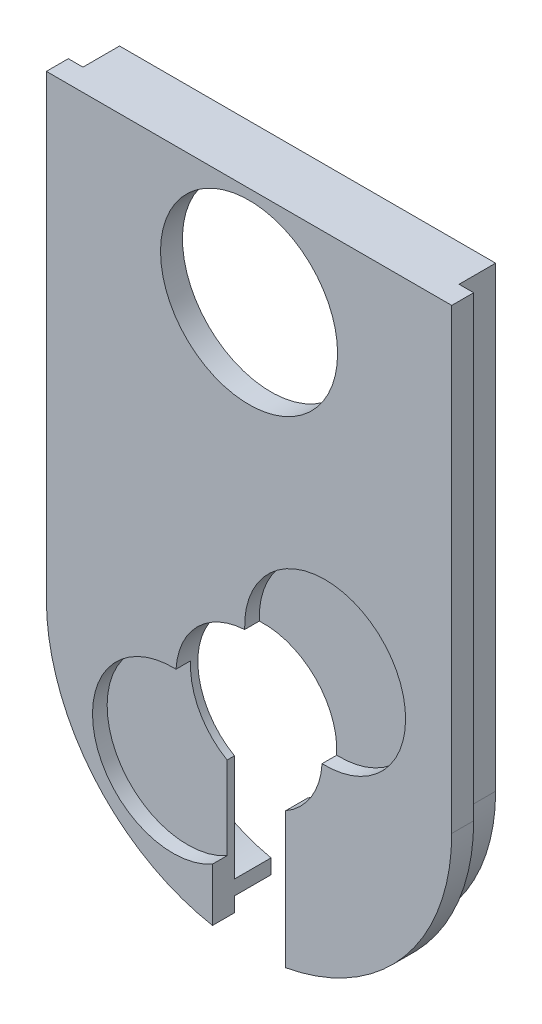
from build123d import *

# Parameters (mm, degrees)
SKETCH1_R           = 27.7
BOSS_EXTRUDE1_DEPTH = 3
SKETCH2_R           = 11
CUT_EXTRUDE1_DEPTH  = 2
SKETCH4_R           = 10
CUT_EXTRUDE2_DEPTH  = 3
SKETCH5_R           = 12.1
BOSS_EXTRUDE3_DEPTH = 3
SKETCH6_W           = 10
SKETCH6_H           = 27.7
CUT_EXTRUDE3_DEPTH  = 3
BOSS_EXTRUDE4_DEPTH = 5


with BuildPart() as part:
    # Sketch1 → Boss-Extrude1 (new body)
    with BuildSketch(Plane.XY):
        Circle(SKETCH1_R)
    extrude(amount=BOSS_EXTRUDE1_DEPTH)

    # Sketch2 → Cut-Extrude1 (cut)
    with BuildSketch(Plane.XY.offset(3)):
        with Locations((-10.394469683, -10.394469683)):
            Circle(SKETCH2_R)
        with Locations((10.394469683, 10.394469683)):
            Circle(SKETCH2_R)
    extrude(amount=-CUT_EXTRUDE1_DEPTH, mode=Mode.SUBTRACT)

    # Sketch4 → Cut-Extrude2 (cut)
    with BuildSketch(Plane.XY.offset(3)):
        Circle(SKETCH4_R)
    extrude(amount=-CUT_EXTRUDE2_DEPTH, mode=Mode.SUBTRACT)

    # Sketch6 → Cut-Extrude3 (cut)
    with BuildSketch(Plane.XY.offset(3)):
        with Locations((0, -13.85)):
            Rectangle(SKETCH6_W, SKETCH6_H)
    extrude(amount=-CUT_EXTRUDE3_DEPTH, mode=Mode.SUBTRACT)



with BuildPart() as body_2:
    # Sketch5 → Boss-Extrude3 (new body)
    with BuildSketch(Plane.XY.offset(3)):
        with BuildLine():
            Line((-27.7, 0), (-27.7, 62.5))
            Line((-27.7, 62.5), (27.7, 62.5))
            Line((27.7, 62.5), (27.7, 0))
            ThreePointArc((27.7, 0), (0, 27.7), (-27.7, 0))
        make_face()
        with Locations((0, 49)):
            Circle(SKETCH5_R, mode=Mode.SUBTRACT)
    extrude(amount=-BOSS_EXTRUDE3_DEPTH)


with BuildPart() as part_1:
    add(part.part)

    add(body_2.part)  # Boss-Extrude4 merges body 2
    # Sketch8 → Boss-Extrude4 (add)
    with BuildSketch(Plane(origin=(0, 0, 0), x_dir=(-1, 0, 0), z_dir=(0, 0, -1))):
        with BuildLine():
            Line((-23.7, 62.5), (23.7, 62.5))
            Line((23.7, 62.5), (25.7, 62.5))
            Line((25.7, 62.5), (25.7, 0))
            ThreePointArc((25.7, 0), (19.863362581, -16.32329625), (5, -25.244999541))
            Line((5, -25.244999541), (5, -23.244999541))
            ThreePointArc((5, -23.244999541), (18.444726934, -14.91660152), (23.7, 0))
            Line((23.7, 0), (23.7, 61.1))
            Line((23.7, 61.1), (-23.7, 61.1))
            Line((-23.7, 61.1), (-23.7, 0))
            ThreePointArc((-23.7, 0), (-18.444726934, -14.91660152), (-5, -23.244999541))
            Line((-5, -23.244999541), (-5, -25.244999541))
            ThreePointArc((-5, -25.244999541), (-19.863362581, -16.32329625), (-25.7, 0))
            Line((-25.7, 0), (-25.7, 62.5))
            Line((-25.7, 62.5), (-23.7, 62.5))
        make_face()
    extrude(amount=BOSS_EXTRUDE4_DEPTH)


solid = part_1.part
